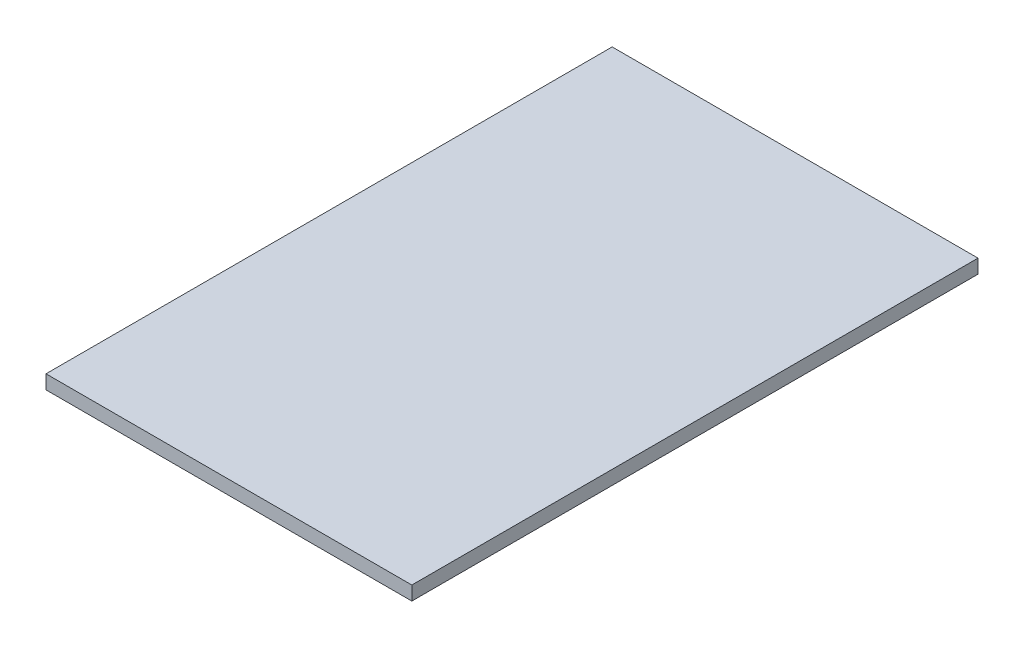
from build123d import *

# Parameters (mm, degrees)
SKETCH1_W           = 42
SKETCH1_H           = 1.6
BOSS_EXTRUDE1_DEPTH = 65


with BuildPart() as part:
    # Sketch1 → Boss-Extrude1 (new body)
    with BuildSketch(Plane.XY):
        with Locations((0, 0.8)):
            Rectangle(SKETCH1_W, SKETCH1_H)
    extrude(amount=BOSS_EXTRUDE1_DEPTH)


solid = part.part
